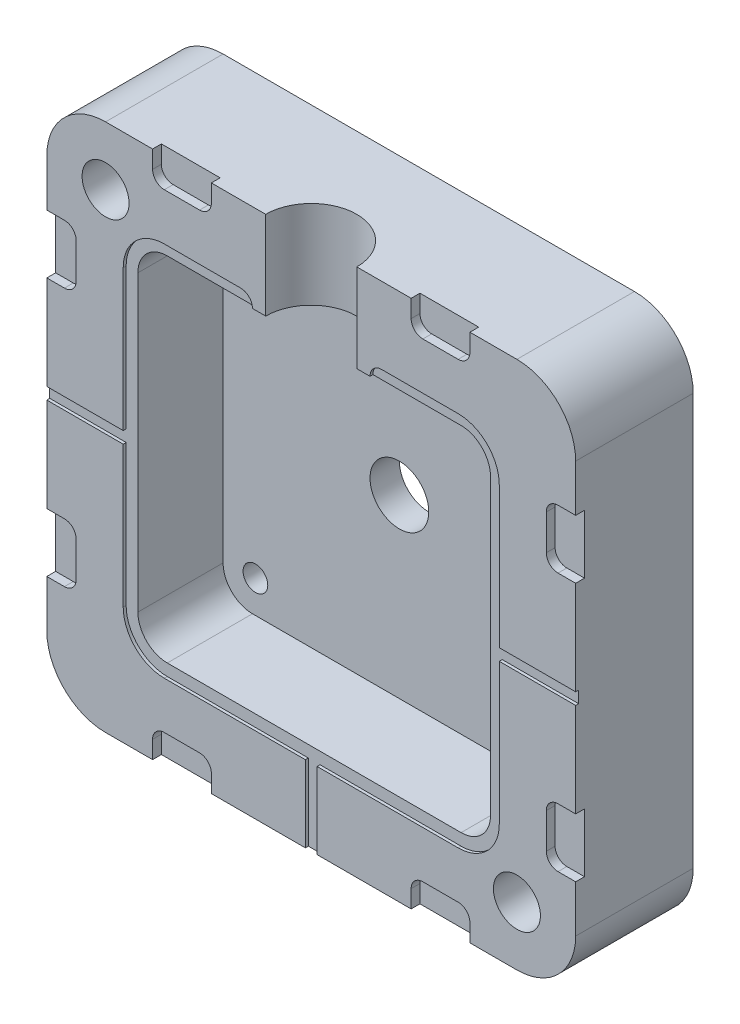
from build123d import *

# Parameters (mm, degrees)
ESQUISSE1_W             = 90
ESQUISSE1_H             = 90
BOSS_EXTRU_1_DEPTH      = 20
ENL_V_MAT_EXTRU_1_DEPTH = 15
ENL_V_MAT_EXTRU_2_DEPTH = 0.5
CONG_1_R                = 10
ESQUISSE6_R             = 4
ENL_V_MAT_EXTRU_4_DEPTH = 21
ESQUISSE7_R             = 5
ENL_V_MAT_EXTRU_5_DEPTH = 6
ENL_V_MAT_EXTRU_6_DEPTH = 1.5
TROU_TARAUD_M51_D       = 4.2
TROU_TARAUD_M51_DEPTH   = 14
TROU_TARAUD_M51_TIP     = 1.2618073
ENL_V_MAT_EXTRU_7_REACH = 92
ESQUISSE4_R             = 7.75


with BuildPart() as part:
    # Esquisse1 → Boss.-Extru.1 (new body)
    with BuildSketch(Plane.XY):
        Rectangle(ESQUISSE1_W, ESQUISSE1_H)
    extrude(amount=BOSS_EXTRU_1_DEPTH)

    # Esquisse2 → Enlèv. mat.-Extru.1 (cut)
    with BuildSketch(Plane.XY.offset(20)):
        with BuildLine():
            Line((-25, -30), (25, -30))
            ThreePointArc((25, -30), (28.535533906, -28.535533906), (30, -25))
            Line((30, -25), (30, 25))
            ThreePointArc((30, 25), (28.535533906, 28.535533906), (25, 30))
            Line((25, 30), (-25, 30))
            ThreePointArc((-25, 30), (-28.535533906, 28.535533906), (-30, 25))
            Line((-30, 25), (-30, -25))
            ThreePointArc((-30, -25), (-28.535533906, -28.535533906), (-25, -30))
        make_face()
    extrude(amount=-ENL_V_MAT_EXTRU_1_DEPTH, mode=Mode.SUBTRACT)

    # Esquisse3 → Enlèv. mat.-Extru.2 (cut)
    with BuildSketch(Plane.XY.offset(20)):
        with BuildLine():
            Line((25, 32), (12, 32))
            ThreePointArc((12, 32), (10.585786438, 31.414213562), (10, 30))
            Line((10, 30), (25, 30))
            ThreePointArc((25, 30), (28.535533906, 28.535533906), (30, 25))
            Line((30, 25), (30, -25))
            ThreePointArc((30, -25), (28.535533906, -28.535533906), (25, -30))
            Line((25, -30), (-25, -30))
            ThreePointArc((-25, -30), (-28.535533906, -28.535533906), (-30, -25))
            Line((-30, -25), (-30, 25))
            ThreePointArc((-30, 25), (-28.535533906, 28.535533906), (-25, 30))
            Line((-25, 30), (-10, 30))
            ThreePointArc((-10, 30), (-10.585786437, 31.414213561), (-11.999999997, 32))
            Line((-11.999999997, 32), (-25, 32))
            ThreePointArc((-25, 32), (-29.949747468, 29.949747468), (-32, 25))
            Line((-32, 25), (-32, 1))
            Line((-32, 1), (-45, 1))
            Line((-45, 1), (-45, -1))
            Line((-45, -1), (-32, -1))
            Line((-32, -1), (-32, -25))
            ThreePointArc((-32, -25), (-29.949747468, -29.949747468), (-25, -32))
            Line((-25, -32), (-1, -32))
            Line((-1, -32), (-1, -45))
            Line((-1, -45), (1, -45))
            Line((1, -45), (1, -32))
            Line((1, -32), (25, -32))
            ThreePointArc((25, -32), (29.949747468, -29.949747468), (32, -25))
            Line((32, -25), (32, -1))
            Line((32, -1), (45, -1))
            Line((45, -1), (45, 1))
            Line((45, 1), (32, 1))
            Line((32, 1), (32, 25))
            ThreePointArc((32, 25), (29.949747468, 29.949747468), (25, 32))
        make_face()
    extrude(amount=-ENL_V_MAT_EXTRU_2_DEPTH, mode=Mode.SUBTRACT)

    # Congé1
    cong_1_edges = [part.edges().sort_by_distance(p)[0] for p in [
        (45, -45, 10),
        (-45, -45, 10),
        (-45, 45, 10),
        (45, 45, 10),
    ]]
    fillet(cong_1_edges, radius=CONG_1_R)

    # Esquisse6 → Enlèv. mat.-Extru.4 (cut, through all)
    with BuildSketch(Plane.XY.offset(20)):
        with Locations((-35, 35)):
            Circle(ESQUISSE6_R)
        with Locations((35, -35)):
            Circle(ESQUISSE6_R)
    extrude(amount=-ENL_V_MAT_EXTRU_4_DEPTH, mode=Mode.SUBTRACT)

    # Esquisse7 → Enlèv. mat.-Extru.5 (cut, through all)
    with BuildSketch(Plane.XY.offset(5)):
        Circle(ESQUISSE7_R)
    extrude(amount=-ENL_V_MAT_EXTRU_5_DEPTH, mode=Mode.SUBTRACT)

    # Esquisse8 → Enlèv. mat.-Extru.6 (cut)
    with BuildSketch(Plane.XY.offset(20)):
        with BuildLine():
            Line((-27, 45), (-17, 45))
            Line((-17, 45), (-17, 42))
            ThreePointArc((-17, 42), (-17.585786438, 40.585786438), (-19, 40))
            Line((-19, 40), (-25, 40))
            ThreePointArc((-25, 40), (-26.414213562, 40.585786438), (-27, 42))
            Line((-27, 42), (-27, 45))
        make_face()
        with BuildLine():
            Line((17, 45), (27, 45))
            Line((27, 45), (27, 42))
            ThreePointArc((27, 42), (26.414213562, 40.585786438), (25, 40))
            Line((25, 40), (19, 40))
            ThreePointArc((19, 40), (17.585786438, 40.585786438), (17, 42))
            Line((17, 42), (17, 45))
        make_face()
        with BuildLine():
            Line((45, 27), (42, 27))
            ThreePointArc((42, 27), (40.585786438, 26.414213562), (40, 25))
            Line((40, 25), (40, 19))
            ThreePointArc((40, 19), (40.585786438, 17.585786438), (42, 17))
            Line((42, 17), (45, 17))
            Line((45, 17), (45, 27))
        make_face()
        with BuildLine():
            Line((45, -17), (42, -17))
            ThreePointArc((42, -17), (40.585786438, -17.585786438), (40, -19))
            Line((40, -19), (40, -25))
            ThreePointArc((40, -25), (40.585786438, -26.414213562), (42, -27))
            Line((42, -27), (45, -27))
            Line((45, -27), (45, -17))
        make_face()
        with BuildLine():
            Line((27, -45), (27, -42))
            ThreePointArc((27, -42), (26.414213562, -40.585786438), (25, -40))
            Line((25, -40), (19, -40))
            ThreePointArc((19, -40), (17.585786438, -40.585786438), (17, -42))
            Line((17, -42), (17, -45))
            Line((17, -45), (27, -45))
        make_face()
        with BuildLine():
            Line((-17, -45), (-17, -42))
            ThreePointArc((-17, -42), (-17.585786438, -40.585786438), (-19, -40))
            Line((-19, -40), (-25, -40))
            ThreePointArc((-25, -40), (-26.414213562, -40.585786438), (-27, -42))
            Line((-27, -42), (-27, -45))
            Line((-27, -45), (-17, -45))
        make_face()
        with BuildLine():
            Line((-45, -27), (-42, -27))
            ThreePointArc((-42, -27), (-40.585786438, -26.414213562), (-40, -25))
            Line((-40, -25), (-40, -19))
            ThreePointArc((-40, -19), (-40.585786438, -17.585786438), (-42, -17))
            Line((-42, -17), (-45, -17))
            Line((-45, -17), (-45, -27))
        make_face()
        with BuildLine():
            Line((-45, 17), (-42, 17))
            ThreePointArc((-42, 17), (-40.585786438, 17.585786438), (-40, 19))
            Line((-40, 19), (-40, 25))
            ThreePointArc((-40, 25), (-40.585786438, 26.414213562), (-42, 27))
            Line((-42, 27), (-45, 27))
            Line((-45, 27), (-45, 17))
        make_face()
    extrude(amount=-ENL_V_MAT_EXTRU_6_DEPTH, mode=Mode.SUBTRACT)

    # Trou taraudé M51
    with Locations(Plane(origin=(-24.5, 24.5, 5), x_dir=(1, 0, 0), z_dir=(0, 0, 1))):
        with Locations((0, 0), (49, 0), (49, -49), (0, -49)):
            Hole(TROU_TARAUD_M51_D / 2, depth=TROU_TARAUD_M51_DEPTH)
            with Locations((0, 0, -(TROU_TARAUD_M51_DEPTH + TROU_TARAUD_M51_TIP / 2))):  # 118° drill point
                Cone(0, TROU_TARAUD_M51_D / 2, TROU_TARAUD_M51_TIP, mode=Mode.SUBTRACT)

    # Esquisse4 → Enlèv. mat.-Extru.7 (cut, up to next)
    with BuildSketch(Plane(origin=(0, 45, 0), x_dir=(1, 0, 0), z_dir=(0, 1, 0)), mode=Mode.PRIVATE) as enl_v_mat_extru_7_sk1:
        with Locations((0, -20)):
            Circle(ESQUISSE4_R)
    enl_v_mat_extru_7_tool1 = extrude(enl_v_mat_extru_7_sk1.sketch, amount=-ENL_V_MAT_EXTRU_7_REACH, mode=Mode.PRIVATE) & part.part
    add(enl_v_mat_extru_7_tool1.solids().sort_by_distance((0, 45, 20))[0], mode=Mode.SUBTRACT)


solid = part.part
